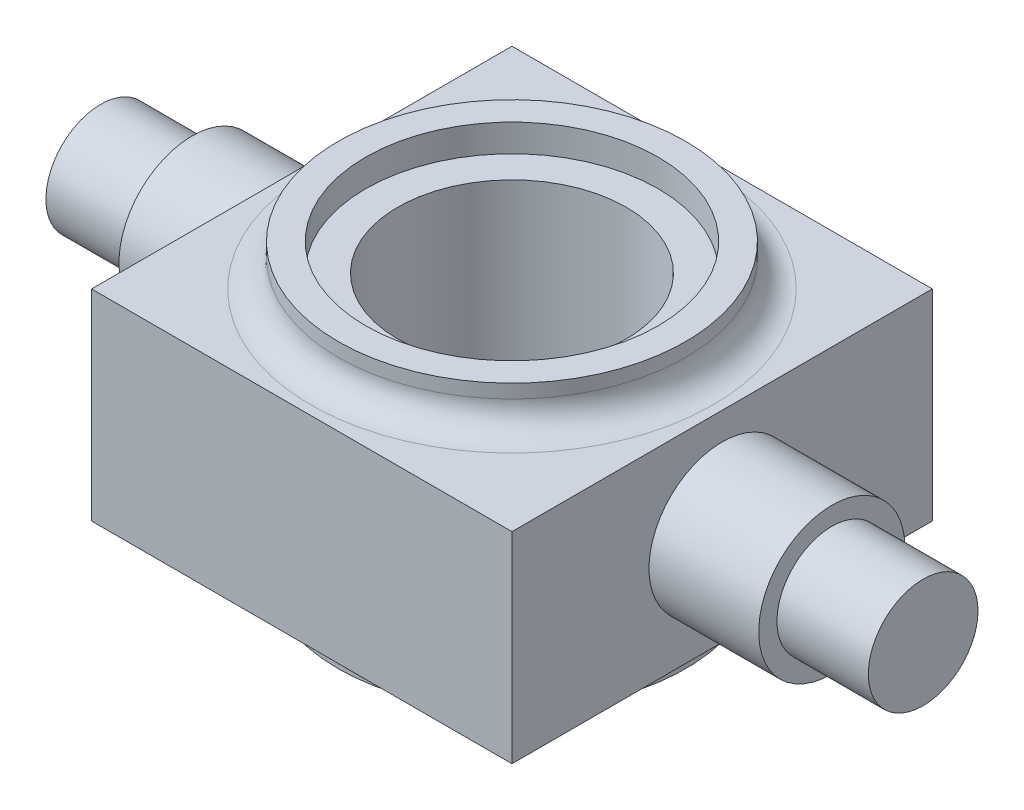
from build123d import *

# Parameters (mm, degrees)
SKETCH1_W           = 46
SKETCH1_H           = 46
BOSS_EXTRUDE1_DEPTH = 11
SKETCH3_R           = 19
BOSS_EXTRUDE3_DEPTH = 4.5
CUT_EXTRUDE1_START  = -3
SKETCH4_R           = 16
CUT_EXTRUDE1_DEPTH  = 48.933283877
SKETCH5_R           = 12.5
CUT_EXTRUDE2_DEPTH  = 43.918527468
SKETCH6_R           = 8
BOSS_EXTRUDE4_DEPTH = 12
SKETCH6_3_R         = 6
BOSS_EXTRUDE5_DEPTH = 22
FILLET1_R           = 3


with BuildPart() as part:
    # Sketch1 → Boss-Extrude1 (new, symmetric)
    with BuildSketch(Plane(origin=(0, 0, 0), x_dir=(1, 0, 0), z_dir=(0, 1, 0))):
        Rectangle(SKETCH1_W, SKETCH1_H)
    extrude(amount=BOSS_EXTRUDE1_DEPTH, both=True)

    # Sketch3 → Boss-Extrude3 (add)
    with BuildSketch(Plane(origin=(0, 11, 0), x_dir=(1, 0, 0), z_dir=(0, 1, 0))):
        Circle(SKETCH3_R)
    boss_extrude3 = extrude(amount=BOSS_EXTRUDE3_DEPTH)

    # Mirror1: Boss-Extrude3 across plane
    add(boss_extrude3.mirror(Plane.ZX))

    # Sketch4 → Cut-Extrude1 (cut)
    with BuildSketch(Plane(origin=(0, 15.5, 0), x_dir=(1, 0, 0), z_dir=(0, 1, 0)).offset(CUT_EXTRUDE1_START)):
        Circle(SKETCH4_R)
    cut_extrude1 = extrude(amount=CUT_EXTRUDE1_DEPTH, mode=Mode.SUBTRACT)

    # Mirror2: Cut-Extrude1 across plane
    add(cut_extrude1.mirror(Plane.ZX), mode=Mode.SUBTRACT)

    # Sketch5 → Cut-Extrude2 (cut, through all)
    with BuildSketch(Plane(origin=(0, 12.5, 0), x_dir=(1, 0, 0), z_dir=(0, 1, 0))):
        Circle(SKETCH5_R)
    extrude(amount=-CUT_EXTRUDE2_DEPTH, mode=Mode.SUBTRACT)

    # Sketch6 → Boss-Extrude4 (add)
    with BuildSketch(Plane(origin=(23, 0, 0), x_dir=(0, 0, -1), z_dir=(1, 0, 0))):
        Circle(SKETCH6_R)
    boss_extrude4 = extrude(amount=BOSS_EXTRUDE4_DEPTH)

    # Sketch6_3 → Boss-Extrude5 (add)
    with BuildSketch(Plane(origin=(23, 0, 0), x_dir=(0, 0, -1), z_dir=(1, 0, 0))):
        Circle(SKETCH6_3_R)
    boss_extrude5 = extrude(amount=BOSS_EXTRUDE5_DEPTH)

    # Mirror3: Boss-Extrude4, Boss-Extrude5 across plane
    add(boss_extrude4.mirror(Plane(origin=(0, 0, 0), x_dir=(0, 0, 1), z_dir=(1, 0, 0))))
    add(boss_extrude5.mirror(Plane(origin=(0, 0, 0), x_dir=(0, 0, 1), z_dir=(1, 0, 0))))

    # Fillet1
    fillet1_edges = [part.edges().sort_by_distance(p)[0] for p in [
        (-19, -11, 0),
        (-19, 11, 0),
    ]]
    fillet(fillet1_edges, radius=FILLET1_R)


solid = part.part
